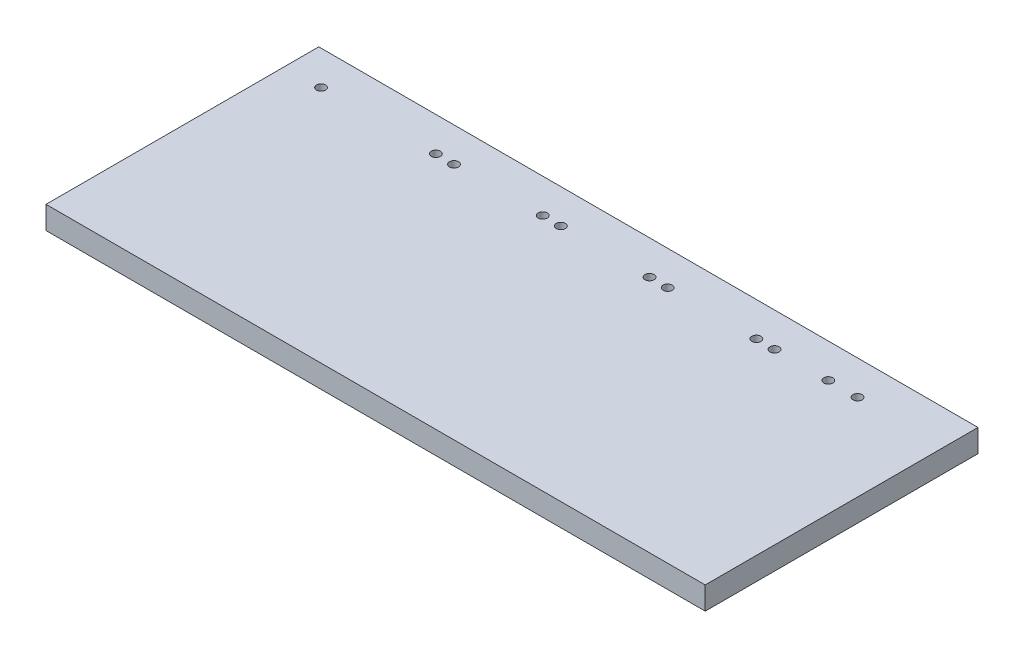
from build123d import *

# Parameters (mm, degrees)
SKETCH_1_W          = 290
SKETCH_1_H          = 120
EXTRUDE_1_DEPTH     = 10
SKETCH_2_R          = 2
CUT_EXTRUDE_1_DEPTH = 11


with BuildPart() as part:
    # Эскиз1 → Бобышка-Вытянуть1 (new body)
    with BuildSketch(Plane(origin=(0, 0, 0), x_dir=(1, 0, 0), z_dir=(0, 1, 0))):
        with Locations((145, 60)):
            Rectangle(SKETCH_1_W, SKETCH_1_H)
    extrude(amount=EXTRUDE_1_DEPTH)

    # Эскиз2 → Вырез-Вытянуть1 (cut, through all)
    with BuildSketch(Plane(origin=(0, 10, 0), x_dir=(1, 0, 0), z_dir=(0, 1, 0))):
        with Locations((16, 105)):
            Circle(SKETCH_2_R)
        with Locations((252, 105)):
            Circle(SKETCH_2_R)
        with Locations((66.5, 105)):
            Circle(SKETCH_2_R)
        with Locations((74.5, 105)):
            Circle(SKETCH_2_R)
        with Locations((113.5, 105)):
            Circle(SKETCH_2_R)
        with Locations((121.5, 105)):
            Circle(SKETCH_2_R)
        with Locations((160.5, 105)):
            Circle(SKETCH_2_R)
        with Locations((168.5, 105)):
            Circle(SKETCH_2_R)
        with Locations((207.5, 105)):
            Circle(SKETCH_2_R)
        with Locations((215.5, 105)):
            Circle(SKETCH_2_R)
        with Locations((239.16098685, 105)):
            Circle(SKETCH_2_R)
    extrude(amount=-CUT_EXTRUDE_1_DEPTH, mode=Mode.SUBTRACT)


solid = part.part
